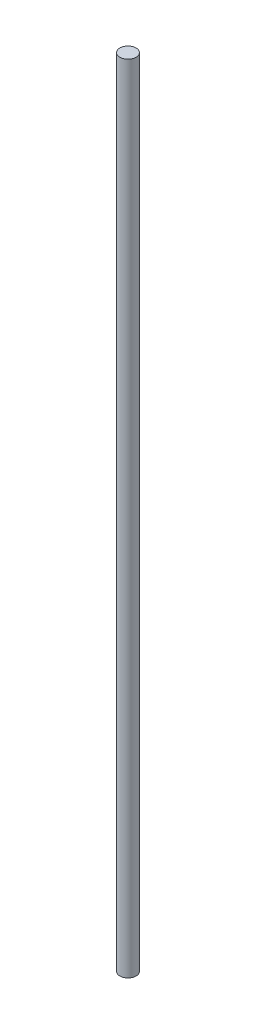
from build123d import *

# Parameters (mm, degrees)
SKETCH1_R           = 4.0005
BOSS_EXTRUDE1_DEPTH = 393.7


with BuildPart() as part:
    # Sketch1 → Boss-Extrude1 (new body)
    with BuildSketch(Plane(origin=(0, 0, 0), x_dir=(1, 0, 0), z_dir=(0, 1, 0))):
        Circle(SKETCH1_R)
    extrude(amount=BOSS_EXTRUDE1_DEPTH)


solid = part.part
